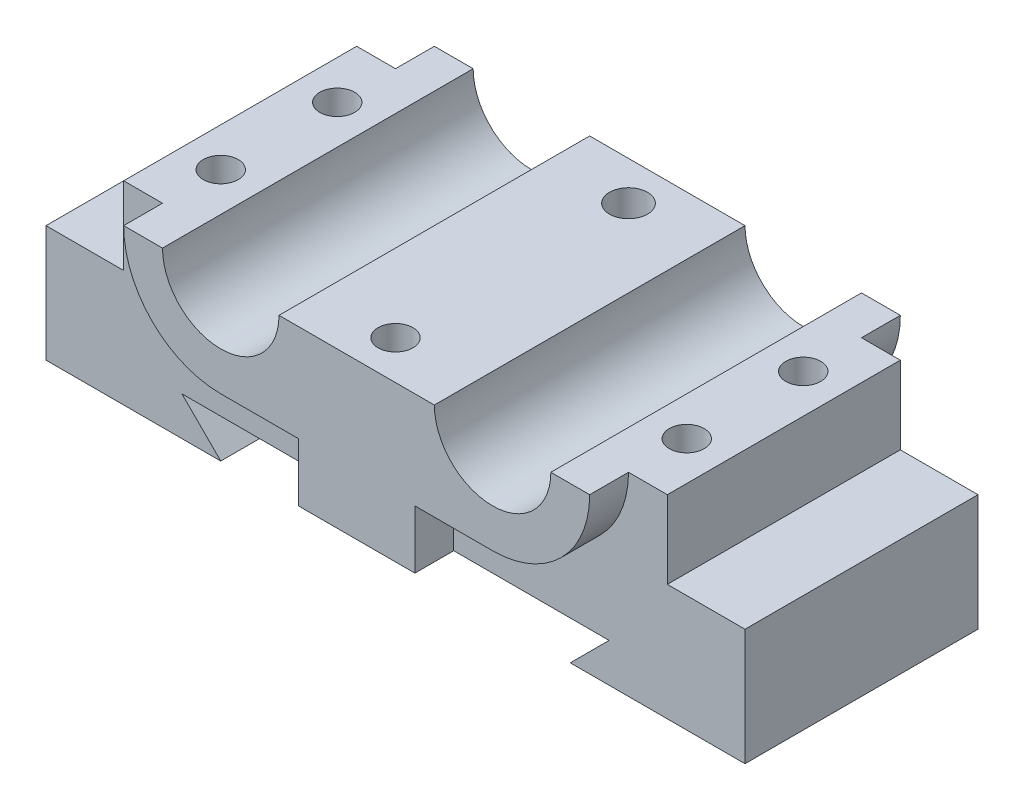
from build123d import *

# Parameters (mm, degrees)
BOSS_EXTRUDE2_DEPTH = 30
BOSS_EXTRUDE3_DEPTH = 5
BOSS_EXTRUDE4_DEPTH = 5
SKETCH5_R           = 2.25
SKETCH5_R_2         = 2.445661488
CUT_EXTRUDE2_DEPTH  = 15


with BuildPart() as part:
    # Sketch1 → Boss-Extrude2 (new body)
    with BuildSketch(Plane.XY):
        with BuildLine():
            Line((0, 0), (0, 15))
            Line((0, 15), (10, 15))
            Line((10, 15), (10, 25))
            Line((10, 25), (20, 25))
            ThreePointArc((20, 25), (27.5, 17.5), (35, 25))
            Line((35, 25), (55, 25))
            ThreePointArc((55, 25), (62.5, 17.5), (70, 25))
            Line((70, 25), (80, 25))
            Line((80, 25), (80, 15))
            Line((80, 15), (90, 15))
            Line((90, 15), (90, 0))
            Line((90, 0), (67.5, 0))
            Line((67.5, 0), (72.5, 5))
            Line((72.5, 5), (17.5, 5))
            Line((17.5, 5), (22.5, 0))
            Line((22.5, 0), (0, 0))
        make_face()
    extrude(amount=BOSS_EXTRUDE2_DEPTH)

    # Sketch3 → Boss-Extrude3 (add)
    with BuildSketch(Plane.XY.offset(30)):
        with BuildLine():
            Line((70, 25), (75, 25))
            ThreePointArc((75, 25), (71.338834765, 16.161165235), (62.5, 12.5))
            Line((62.5, 12.5), (52.5, 12.5))
            Line((52.5, 12.5), (52.5, 5))
            Line((52.5, 5), (37.5, 5))
            Line((37.5, 5), (37.5, 12.5))
            Line((37.5, 12.5), (27.5, 12.5))
            ThreePointArc((27.5, 12.5), (18.661165235, 16.161165235), (15, 25))
            Line((15, 25), (20, 25))
            ThreePointArc((20, 25), (27.5, 17.5), (35, 25))
            Line((35, 25), (55, 25))
            ThreePointArc((55, 25), (62.5, 17.5), (70, 25))
        make_face()
    extrude(amount=BOSS_EXTRUDE3_DEPTH)

    # Sketch4 → Boss-Extrude4 (add)
    with BuildSketch(Plane(origin=(0, 0, 0), x_dir=(-1, 0, 0), z_dir=(0, 0, -1))):
        with BuildLine():
            Line((-62.5, 12.5), (-52.5, 12.5))
            Line((-52.5, 12.5), (-52.5, 5))
            Line((-52.5, 5), (-37.5, 5))
            Line((-37.5, 5), (-37.5, 12.5))
            Line((-37.5, 12.5), (-27.5, 12.5))
            ThreePointArc((-27.5, 12.5), (-18.661165235, 16.161165235), (-15, 25))
            Line((-15, 25), (-20, 25))
            ThreePointArc((-20, 25), (-27.5, 17.5), (-35, 25))
            Line((-35, 25), (-55, 25))
            ThreePointArc((-55, 25), (-62.5, 17.5), (-70, 25))
            Line((-70, 25), (-75, 25))
            ThreePointArc((-75, 25), (-71.338834765, 16.161165235), (-62.5, 12.5))
        make_face()
    extrude(amount=BOSS_EXTRUDE4_DEPTH)

    # Sketch5 → Cut-Extrude2 (cut)
    with BuildSketch(Plane(origin=(0, 25, 0), x_dir=(1, 0, 0), z_dir=(0, 1, 0))):
        with Locations((75, -7.5)):
            Circle(SKETCH5_R)
        with Locations((75, -22.5)):
            Circle(SKETCH5_R)
        with Locations((15, -22.5)):
            Circle(SKETCH5_R)
        with Locations((15, -7.5)):
            Circle(SKETCH5_R)
        with Locations((45, 0)):
            Circle(SKETCH5_R_2)
        with Locations((45, -30)):
            Circle(SKETCH5_R)
    extrude(amount=-CUT_EXTRUDE2_DEPTH, mode=Mode.SUBTRACT)


solid = part.part
